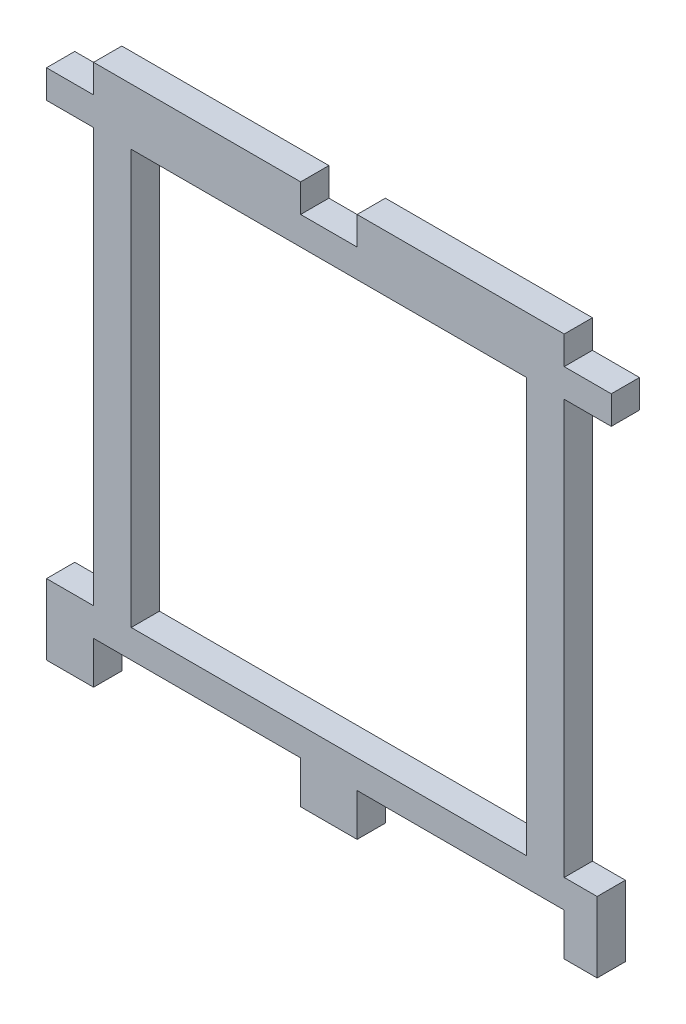
from build123d import *

# Parameters (mm, degrees)
SKETCH1_W           = 42
SKETCH1_H           = 44
BOSS_EXTRUDE1_DEPTH = 3


with BuildPart() as part:
    # Sketch1 → Boss-Extrude1 (new body)
    with BuildSketch(Plane.XY):
        Polygon((0, 0), (5, 0), (5, 3), (27, 3), (27, 0), (33, 0), (33, 3), (55, 3), (55, 0), (60, 0), (60, -3), (55, -3), (55, -47), (58.5, -47), (58.5, -54.5), (55, -54.5), (55, -50), (33, -50), (33, -54.5), (27, -54.5), (27, -50), (5, -50), (5, -54.5), (0, -54.5), (0, -47), (5, -47), (5, -3), (0, -3), align=None)
        with Locations((30, -25)):
            Rectangle(SKETCH1_W, SKETCH1_H, mode=Mode.SUBTRACT)
    extrude(amount=BOSS_EXTRUDE1_DEPTH)


solid = part.part
